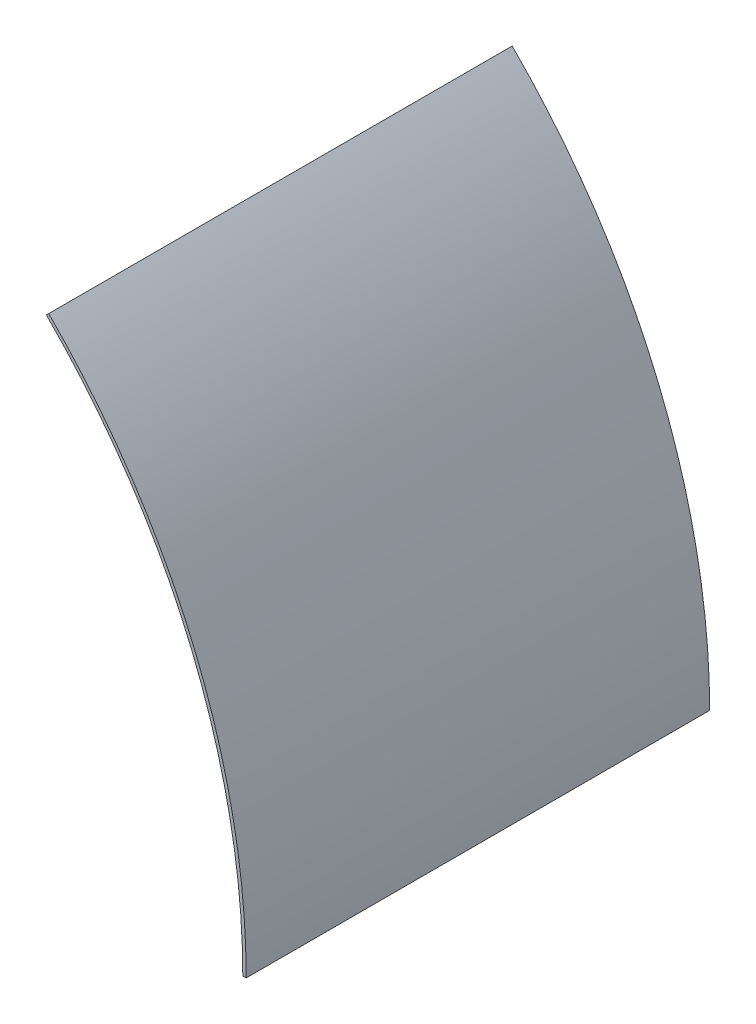
from build123d import *

# Parameters (mm, degrees)
BOSS_EXTRUDE1_DEPTH = 174.625


with BuildPart() as part:
    # Sketch1 → Boss-Extrude1 (new body)
    with BuildSketch(Plane.XY):
        with BuildLine():
            Line((179.605122421, 179.605122421), (178.707096809, 178.707096809))
            ThreePointArc((178.707096809, 178.707096809), (233.492074252, 96.715583862), (252.73, 0))
            Line((252.73, 0), (254, 0))
            ThreePointArc((254, 0), (234.665401258, 97.201591821), (179.605122421, 179.605122421))
        make_face()
    extrude(amount=BOSS_EXTRUDE1_DEPTH)


solid = part.part
